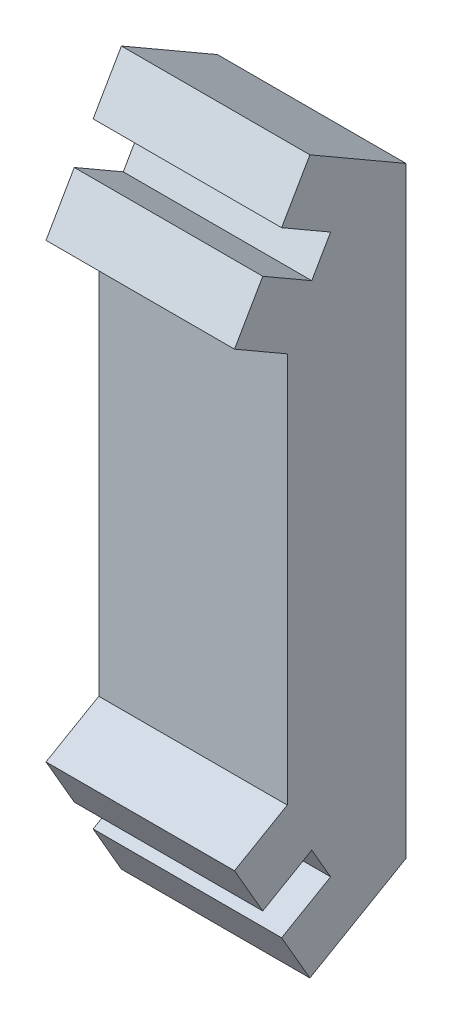
from build123d import *

# Parameters (mm, degrees)
EXTRUDE_1_DEPTH = 10


with BuildPart() as part:
    # Эскиз1 → Бобышка-Вытянуть1 (new body)
    with BuildSketch(Plane(origin=(0, 0, 0), x_dir=(0, 0, -1), z_dir=(1, 0, 0))):
        Polygon((-2.039845048, 21.046884737), (-4.637921259, 22.546884737), (-6.137921259, 19.948808526), (-3.338883154, 18.332783122), (-3.338883154, -2.399013647), (-6.137921259, -4.015039051), (-4.637921259, -6.613115263), (-2.039845048, -5.113115263), (-1.039845048, -6.84516607), (-2.338883154, -7.59516607), (-3.637921259, -8.34516607), (-2.137921259, -10.943242281), (2.960154952, -7.999866609), (2.960154952, 23.933636083), (-2.137921259, 26.877011756), (-3.637921259, 24.278935545), (-2.338883154, 23.528935545), (-1.039845048, 22.778935545), align=None)
    extrude(amount=EXTRUDE_1_DEPTH)


solid = part.part
